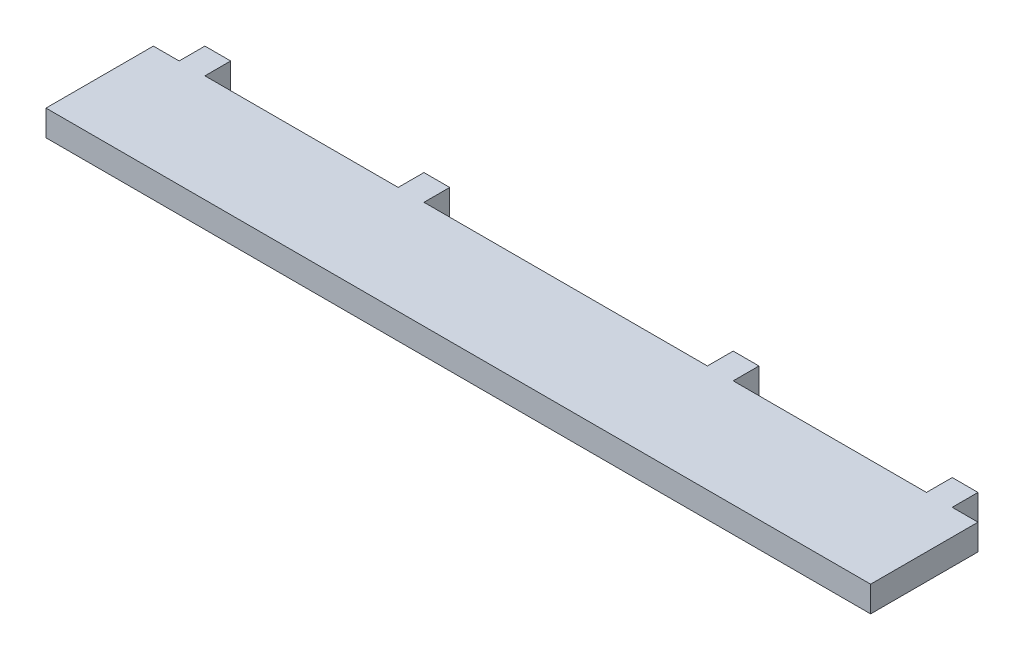
from build123d import *

# Parameters (mm, degrees)
SKETCH1_W           = 192
SKETCH1_H           = 6
BOSS_EXTRUDE1_DEPTH = 25
SKETCH2_W           = 6
SKETCH2_H           = 6
BOSS_EXTRUDE3_DEPTH = 6


with BuildPart() as part:
    # Sketch1 → Boss-Extrude1 (new body)
    with BuildSketch(Plane.XY):
        with Locations((0, 3)):
            Rectangle(SKETCH1_W, SKETCH1_H)
    extrude(amount=BOSS_EXTRUDE1_DEPTH)

    # Sketch2 → Boss-Extrude3 (add)
    with BuildSketch(Plane(origin=(0, 0, 0), x_dir=(1, 0, 0), z_dir=(0, 1, 0))):
        with Locations((-87, 3)):
            Rectangle(SKETCH2_W, SKETCH2_H)
        with Locations((-36, 3)):
            Rectangle(SKETCH2_W, SKETCH2_H)
        with Locations((36, 3)):
            Rectangle(SKETCH2_W, SKETCH2_H)
        with Locations((87, 3)):
            Rectangle(SKETCH2_W, SKETCH2_H)
    extrude(amount=BOSS_EXTRUDE3_DEPTH)


solid = part.part
